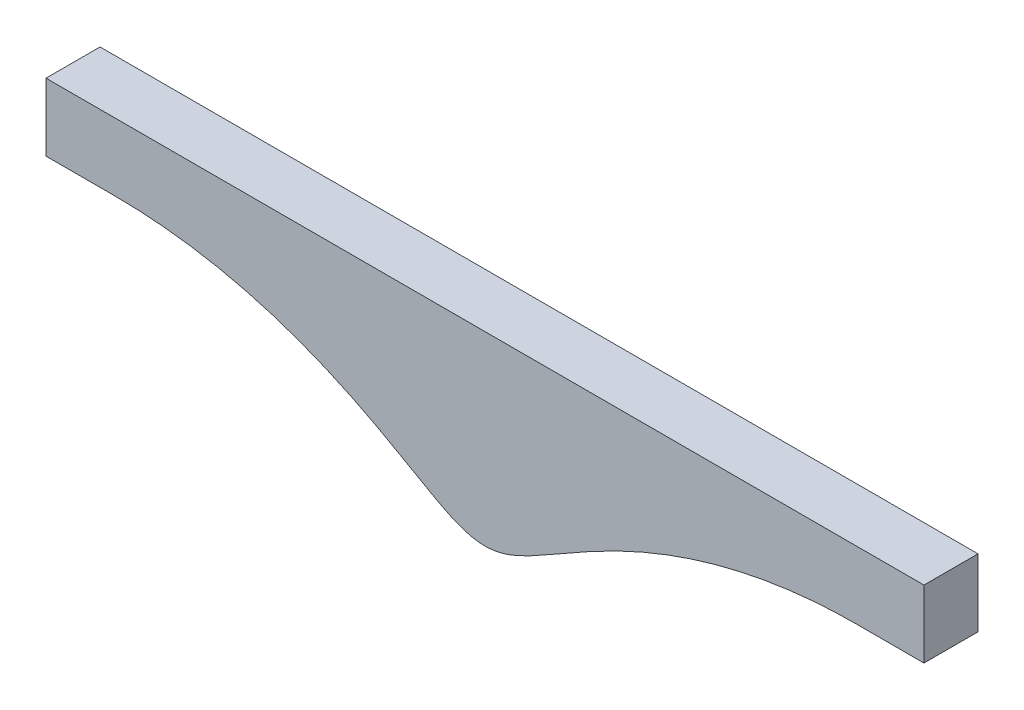
from build123d import *

# Parameters (mm, degrees)
BOSS_EXTRUDE1_DEPTH = 10.16


with BuildPart() as part:
    # Sketch2 → Boss-Extrude1 (new body)
    with BuildSketch(Plane.XY):
        with BuildLine():
            Line((-69.821896726, 33.3375), (-82.521896726, 33.3375))
            Line((-82.521896726, 33.3375), (-82.521896726, 46.037499958))
            Line((-82.521896726, 46.037499958), (82.521896726, 46.037499958))
            Line((82.521896726, 46.037499958), (82.521896726, 33.337499958))
            Line((82.521896726, 33.337499958), (69.821896726, 33.337499958))
            add(Edge.make_bspline(
                [(-69.821896726, 33.3375), (-69.695748082, 33.337499958), (-69.444014878, 33.33688898), (-68.974776454, 33.334139576), (-68.311523611, 33.326807968), (-67.535738646, 33.313061622), (-66.649871791, 33.289235879), (-65.583119966, 33.250751769), (-64.375109134, 33.192119398), (-63.166065476, 33.118845233), (-61.958257755, 33.030940192), (-60.75156183, 32.928417725), (-58.340858198, 32.694168713), (-55.636700095, 32.354076931), (-52.04746615, 31.784437981), (-47.597259295, 30.87442217), (-44.068683145, 30.003709231), (-40.578319771, 28.992751035), (-37.698257404, 28.058512705), (-35.412490367, 27.256928735), (-33.146112621, 26.402109783), (-30.899989094, 25.495391202), (-28.118713815, 24.298818506), (-24.824137204, 22.766002302), (-21.044263598, 20.845993076), (-16.988495065, 18.604884197), (-13.163922242, 16.384998059), (-9.682433774, 14.378110033), (-6.752766683, 12.839370164), (-4.260575031, 11.818773782), (-2.289648997, 11.300020037), (-0.727513295, 11.098155491), (0.727513365, 11.098155139), (2.289648769, 11.300020508), (4.260575544, 11.818772947), (6.752765579, 12.839371822), (9.682435908, 14.378106921), (13.163918453, 16.385003517), (16.988501351, 18.604875175), (21.044252982, 20.84600832), (25.364138003, 23.040262643), (29.22052055, 24.802279565), (32.579499149, 26.188445915), (35.412494909, 27.256909268), (37.698265231, 28.058522908), (40.578297255, 28.992744505), (44.068728971, 30.00371395), (48.185272464, 31.019537163), (52.346368543, 31.835595144), (55.937275824, 32.390662735), (58.943373068, 32.756370776), (61.353326154, 32.990636746), (63.469107465, 33.144482739), (65.279425319, 33.239756175), (66.64951597, 33.28923593), (67.535784341, 33.313061615), (68.311545278, 33.326807964), (68.974773229, 33.334139576), (69.444018374, 33.33688898), (69.695748082, 33.337499958), (69.821896726, 33.337499958)],
                knots=[0.083325531, 0.083325531, 0.083325531, 0.083325531, 0.083325531, 0.086723077, 0.090120623, 0.093518169, 0.096915715, 0.103710808, 0.1105059, 0.117300992, 0.124096085, 0.130891177, 0.137686269, 0.14448136, 0.178456812, 0.192046993, 0.219227344, 0.246407696, 0.259997928, 0.273588159, 0.287178391, 0.300768623, 0.314358811, 0.327948999, 0.355129375, 0.382309728, 0.409490081, 0.431935904, 0.454381728, 0.472501988, 0.483716791, 0.492234559, 0.5, 0.507765441, 0.516283209, 0.527498012, 0.545618272, 0.568064096, 0.590509919, 0.617690272, 0.644870625, 0.672051001, 0.699231377, 0.712821609, 0.726411841, 0.740002072, 0.753592304, 0.780772656, 0.807953007, 0.835133369, 0.84872355, 0.862313731, 0.875903915, 0.8894941, 0.896289192, 0.903084285, 0.906481831, 0.909879377, 0.913276923, 0.916674469, 0.916674469, 0.916674469, 0.916674469, 0.916674469], degree=4))
        make_face()
    extrude(amount=BOSS_EXTRUDE1_DEPTH)


solid = part.part
